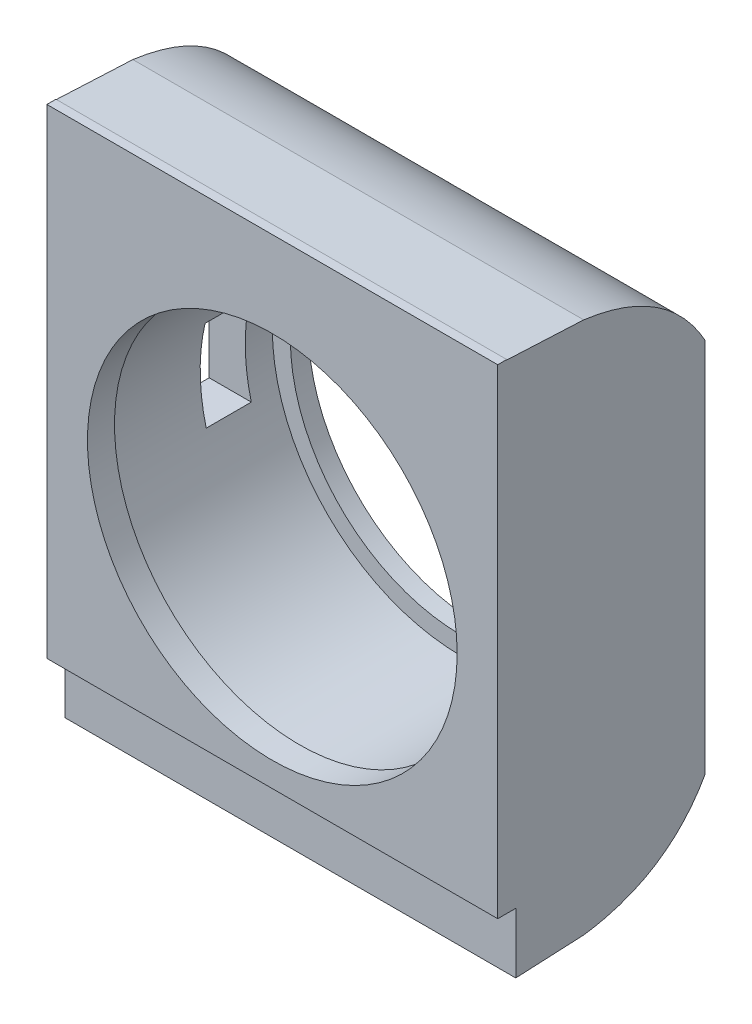
from build123d import *

# Parameters (mm, degrees)
SKETCH2_R                = 21
SKETCH2_R_2              = 18
BOSS_EXTRUDE1_DEPTH      = 2
SKETCH3_R                = 23
SKETCH3_R_2              = 21
BOSS_EXTRUDE2_DEPTH      = 20
BOSS_EXTRUDE4_START      = 20
SKETCH5_W                = 50
SKETCH5_H                = 60
BOSS_EXTRUDE4_DEPTH      = 3
CUT_EXTRUDE5_START       = 20
SKETCH6_R                = 22
CUT_EXTRUDE5_DEPTH       = 5
BOSS_EXTRUDE5_START      = 20
SKETCH7_R                = 22
SKETCH7_R_2              = 20.5
BOSS_EXTRUDE5_DEPTH      = 3
SKETCH11_W               = 50
SKETCH11_H               = 60
SKETCH11_R               = 23
BOSS_EXTRUDE13_DEPTH     = 20
CUT_EXTRUDE8_DEPTH       = 26
CUT_EXTRUDE8_DEPTH_BACK  = 26
SKETCH14_W               = 5
SKETCH14_H               = 10
CUT_EXTRUDE9_DEPTH       = 30
BOSS_EXTRUDE14_START     = 22
SKETCH16_W               = 50
SKETCH16_H               = 53.9
SKETCH16_R               = 21
BOSS_EXTRUDE14_DEPTH     = 5
CUT_EXTRUDE10_DEPTH      = 26.0000001
CUT_EXTRUDE10_DEPTH_BACK = 26.0000001
SKETCH18_W               = 2
SKETCH18_H               = 6.789744693
CUT_EXTRUDE11_DEPTH      = 26.0000001
CUT_EXTRUDE11_DEPTH_BACK = 26.0000001
SKETCH19_R               = 19
SKETCH19_R_2             = 18
CUT_EXTRUDE13_DEPTH      = 24.0000001
CUT_EXTRUDE13_DEPTH_BACK = 1.0000001


with BuildPart() as part:
    # Sketch2 → Boss-Extrude1 (new body)
    with BuildSketch(Plane.XY):
        Circle(SKETCH2_R)
        Circle(SKETCH2_R_2, mode=Mode.SUBTRACT)
    extrude(amount=BOSS_EXTRUDE1_DEPTH)

    # Sketch3 → Boss-Extrude2 (add)
    with BuildSketch(Plane.XY):
        Circle(SKETCH3_R)
        Circle(SKETCH3_R_2, mode=Mode.SUBTRACT)
    extrude(amount=BOSS_EXTRUDE2_DEPTH)

    # Sketch5 → Boss-Extrude4 (add)
    with BuildSketch(Plane.XY.offset(BOSS_EXTRUDE4_START)):
        Rectangle(SKETCH5_W, SKETCH5_H)
    extrude(amount=BOSS_EXTRUDE4_DEPTH)

    # Sketch6 → Cut-Extrude5 (cut)
    with BuildSketch(Plane.XY.offset(CUT_EXTRUDE5_START)):
        Circle(SKETCH6_R)
    extrude(amount=CUT_EXTRUDE5_DEPTH, mode=Mode.SUBTRACT)

    # Sketch7 → Boss-Extrude5 (add)
    with BuildSketch(Plane.XY.offset(BOSS_EXTRUDE5_START)):
        Circle(SKETCH7_R)
        Circle(SKETCH7_R_2, mode=Mode.SUBTRACT)
    extrude(amount=BOSS_EXTRUDE5_DEPTH)

    # Sketch11 → Boss-Extrude13 (add)
    with BuildSketch(Plane.XY):
        Rectangle(SKETCH11_W, SKETCH11_H)
        Circle(SKETCH11_R, mode=Mode.SUBTRACT)
    extrude(amount=BOSS_EXTRUDE13_DEPTH)

    # Sketch13 → Cut-Extrude8 (cut, two sides)
    with BuildSketch(Plane(origin=(0, 0, 0), x_dir=(0, 0, -1), z_dir=(1, 0, 0))) as cut_extrude8_sk:
        with BuildLine():
            Line((-13.469410681, 29.542799808), (-23, 30))
            Line((-23, 30), (-23, 33.892869883))
            Line((-23, 33.892869883), (0, 33.892869883))
            Line((0, 33.892869883), (0, 20.84319904))
            add(Edge.make_bspline(
                [(0, 20.84319904), (-4.171009324, 28.289688325), (-13.469410681, 29.542799808)],
                knots=[0, 0, 0, 1, 1, 1], degree=2))
        make_face()
        with BuildLine():
            Line((-23, -33.892869883), (-23, -30))
            Line((-23, -30), (-13.469410681, -29.542799808))
            add(Edge.make_bspline(
                [(0, -20.84319904), (-4.171009324, -28.289688325), (-13.469410681, -29.542799808)],
                knots=[0, 0, 0, 1, 1, 1], degree=2))
            Line((0, -20.84319904), (0, -33.892869883))
            Line((0, -33.892869883), (-23, -33.892869883))
        make_face()
    extrude(amount=CUT_EXTRUDE8_DEPTH, mode=Mode.SUBTRACT)
    extrude(cut_extrude8_sk.sketch, amount=-CUT_EXTRUDE8_DEPTH_BACK, mode=Mode.SUBTRACT)

    # Sketch14 → Cut-Extrude9 (cut)
    with BuildSketch(Plane(origin=(0, 0, 0), x_dir=(0, 0, -1), z_dir=(1, 0, 0))):
        with Locations((-7.5, -0.257473708)):
            Rectangle(SKETCH14_W, SKETCH14_H)
    extrude(amount=-CUT_EXTRUDE9_DEPTH, mode=Mode.SUBTRACT)

    # Sketch16 → Boss-Extrude14 (add)
    with BuildSketch(Plane.XY.offset(BOSS_EXTRUDE14_START)):
        with Locations((0, 3.05)):
            Rectangle(SKETCH16_W, SKETCH16_H)
        Circle(SKETCH16_R, mode=Mode.SUBTRACT)
    extrude(amount=BOSS_EXTRUDE14_DEPTH)

    # Sketch17 → Cut-Extrude10 (cut, two sides)
    with BuildSketch(Plane(origin=(0, 0, 0), x_dir=(0, 0, -1), z_dir=(1, 0, 0))) as cut_extrude10_sk:
        Polygon((-23, -23.9), (-23, 0), (-23, 35.597390388), (-27, 35.597390388), (-27, -23.9), align=None)
    extrude(amount=CUT_EXTRUDE10_DEPTH, mode=Mode.SUBTRACT)
    extrude(cut_extrude10_sk.sketch, amount=-CUT_EXTRUDE10_DEPTH_BACK, mode=Mode.SUBTRACT)

    # Sketch18 → Cut-Extrude11 (cut, two sides)
    with BuildSketch(Plane(origin=(0, 0, 0), x_dir=(0, 0, -1), z_dir=(1, 0, 0))) as cut_extrude11_sk:
        with Locations((-22, -26.605127654)):
            Rectangle(SKETCH18_W, SKETCH18_H)
    extrude(amount=CUT_EXTRUDE11_DEPTH, mode=Mode.SUBTRACT)
    extrude(cut_extrude11_sk.sketch, amount=-CUT_EXTRUDE11_DEPTH_BACK, mode=Mode.SUBTRACT)

    # Sketch19 → Cut-Extrude13 (cut, two sides)
    with BuildSketch(Plane.XY) as cut_extrude13_sk:
        Circle(SKETCH19_R)
        Circle(SKETCH19_R_2, mode=Mode.SUBTRACT)
    extrude(amount=CUT_EXTRUDE13_DEPTH, mode=Mode.SUBTRACT)
    extrude(cut_extrude13_sk.sketch, amount=-CUT_EXTRUDE13_DEPTH_BACK, mode=Mode.SUBTRACT)


solid = part.part
